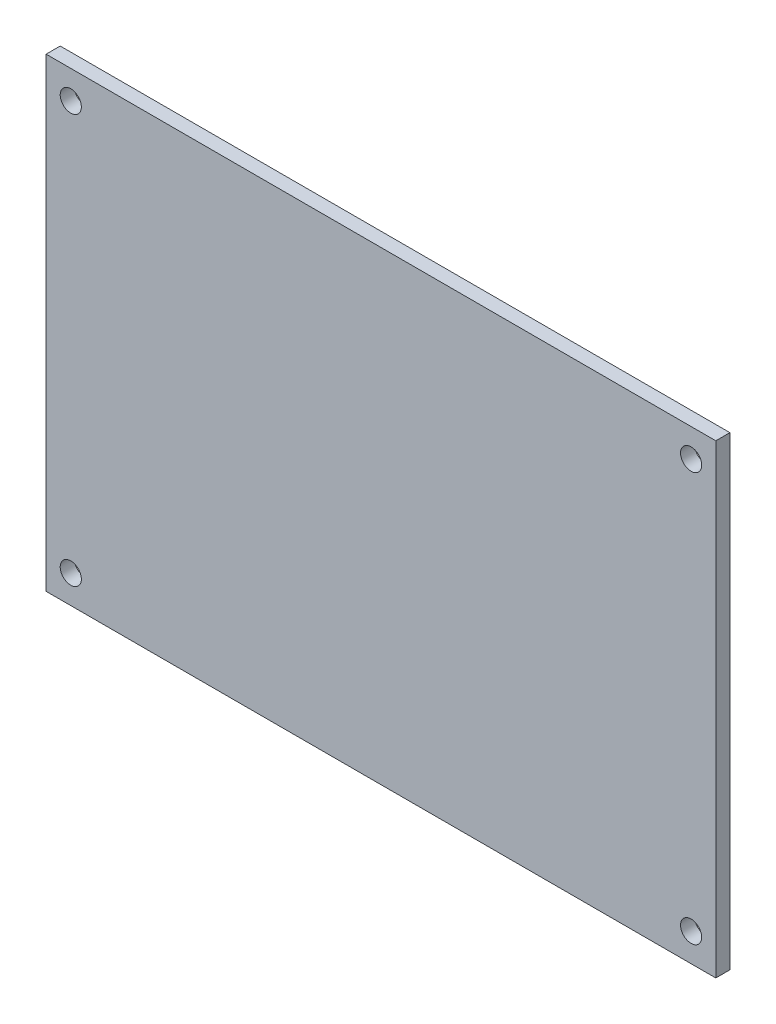
from build123d import *

# Parameters (mm, degrees)
SKETCH1_W           = 95
SKETCH1_H           = 66
BOSS_EXTRUDE1_DEPTH = 2
SKETCH2_R           = 1.5
CUT_EXTRUDE1_DEPTH  = 2


with BuildPart() as part:
    # Sketch1 → Boss-Extrude1 (new body)
    with BuildSketch(Plane.XY):
        with Locations((-47.5, 33)):
            Rectangle(SKETCH1_W, SKETCH1_H)
    extrude(amount=BOSS_EXTRUDE1_DEPTH)

    # Sketch2 → Cut-Extrude1 (cut)
    with BuildSketch(Plane.XY.offset(2)):
        with Locations((-91.5, 62)):
            Circle(SKETCH2_R)
        with Locations((-3.5, 62)):
            Circle(SKETCH2_R)
        with Locations((-3.5, 4)):
            Circle(SKETCH2_R)
        with Locations((-91.5, 4)):
            Circle(SKETCH2_R)
    extrude(amount=-CUT_EXTRUDE1_DEPTH, mode=Mode.SUBTRACT)


solid = part.part
